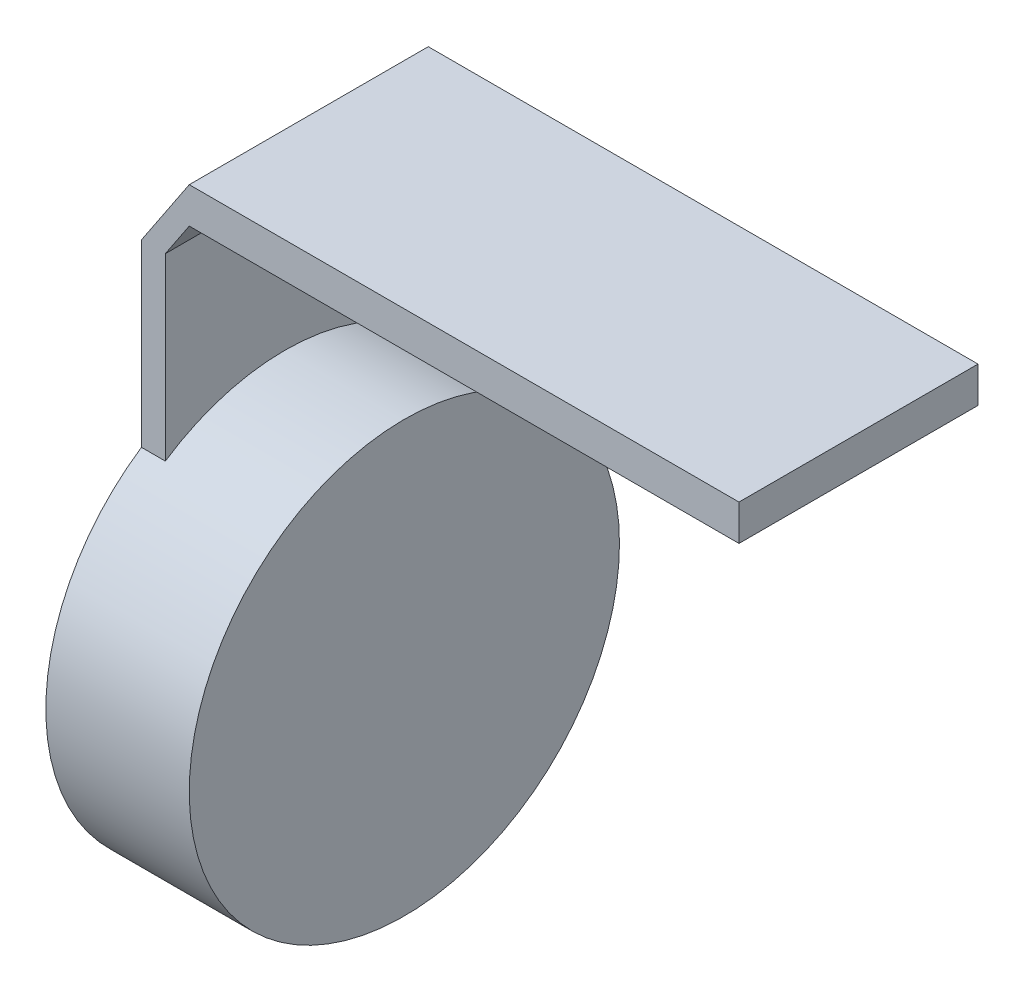
from build123d import *

# Parameters (mm, degrees)
SKETCH1_R           = 18
BOSS_EXTRUDE1_DEPTH = 10
BOSS_EXTRUDE2_DEPTH = 2
BOSS_EXTRUDE4_DEPTH = 20


with BuildPart() as part:
    # Sketch1 → Boss-Extrude1 (new body)
    with BuildSketch(Plane(origin=(0, 0, 0), x_dir=(0, 0, -1), z_dir=(1, 0, 0))):
        Circle(SKETCH1_R)
    extrude(amount=BOSS_EXTRUDE1_DEPTH)

    # Sketch2 → Boss-Extrude2 (add)
    with BuildSketch(Plane.ZY):
        with BuildLine():
            Line((-10, 14.966629547), (-10, 30))
            Line((-10, 30), (10, 30))
            Line((10, 30), (10, 14.966629547))
            ThreePointArc((10, 14.966629547), (0, -18), (-10, 14.966629547))
        make_face()
    extrude(amount=BOSS_EXTRUDE2_DEPTH)

    # Sketch5 → Boss-Extrude4 (add)
    with BuildSketch(Plane(origin=(0, 0, -10), x_dir=(-1, 0, 0), z_dir=(0, 0, -1))):
        Polygon((-2, 36), (-48, 36), (-48, 33), (-2, 33), (0, 30), (0, 14.966629547), (2, 14.966629547), (2, 30), align=None)
    extrude(amount=-BOSS_EXTRUDE4_DEPTH)


solid = part.part
